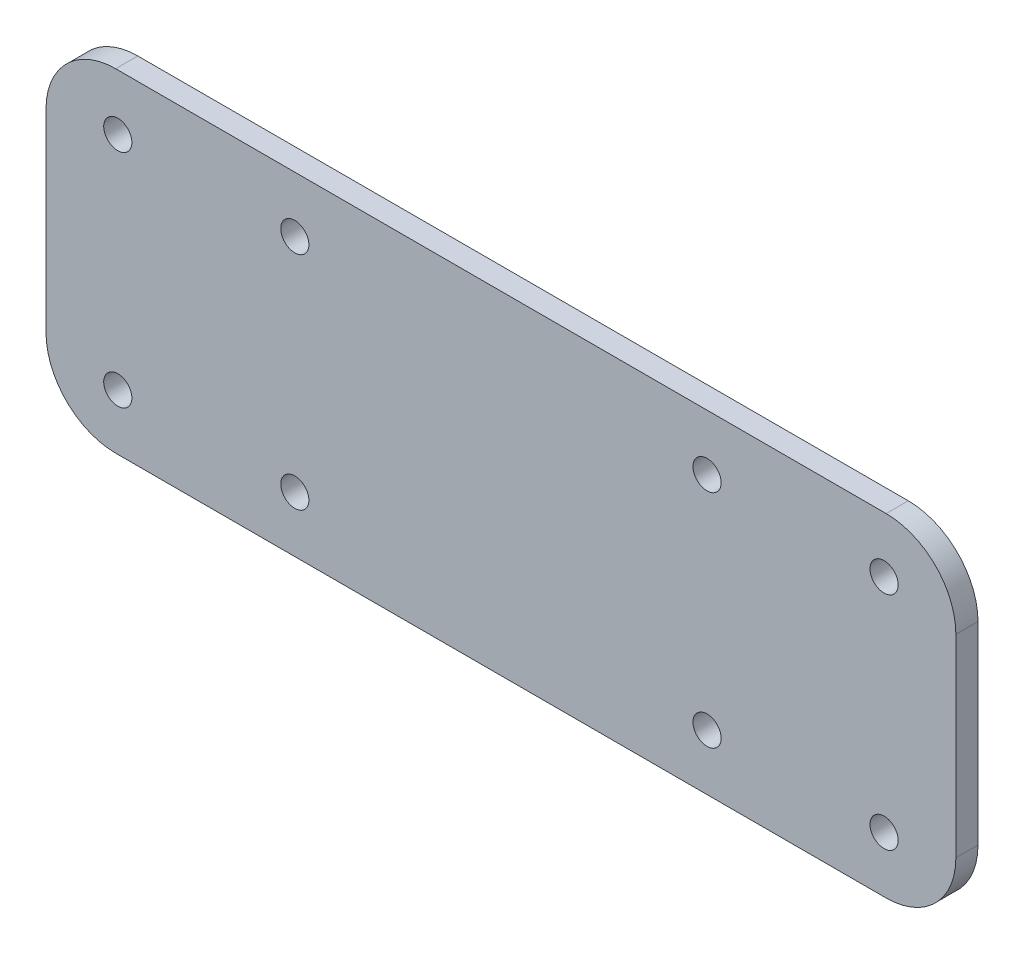
from build123d import *

# Parameters (mm, degrees)
BOSS_EXTRUDE1_DEPTH = 3.175
CUT_EXTRUDE1_DEPTH  = 10
SKETCH3_R           = 2.0193
BOSS_EXTRUDE2_DEPTH = 3.175
FILLET1_R           = 10
FILLET2_R           = 50
SKETCH4_R           = 2.02
CUT_EXTRUDE2_DEPTH  = 10
SKETCH5_R           = 2.0193
BOSS_EXTRUDE3_DEPTH = 3.175
SKETCH6_W           = 3.175
SKETCH6_H           = 346.1216
CUT_EXTRUDE3_DEPTH  = 131.549169731


with BuildPart() as part:
    # Sketch1 → Boss-Extrude1 (new body)
    with BuildSketch(Plane.XY):
        Polygon((165.934536959, -16.66935), (157.315236959, -8.05005), (115.359952094, -8.05005), (89.959952094, -8.05005), (48.004667228, -8.05005), (39.385367228, -16.66935), (39.385367228, -40.05005), (39.385367228, -52.41105), (165.934536959, -56.67505), (165.934536959, -42.05005), align=None)
        with BuildLine():
            ThreePointArc((47.685367228, -44.38075), (49.704667228, -46.40005), (47.685367228, -48.41935))
            ThreePointArc((47.685367228, -48.41935), (45.666067228, -46.40005), (47.685367228, -44.38075))
        make_face(mode=Mode.SUBTRACT)
        with BuildLine():
            ThreePointArc((47.685367228, -12.63075), (49.704667228, -14.65005), (47.685367228, -16.66935))
            ThreePointArc((47.685367228, -16.66935), (45.666067228, -14.65005), (47.685367228, -12.63075))
        make_face(mode=Mode.SUBTRACT)
        with BuildLine():
            ThreePointArc((73.085367228, -44.38075), (75.104667228, -46.40005), (73.085367228, -48.41935))
            ThreePointArc((73.085367228, -48.41935), (71.066067228, -46.40005), (73.085367228, -44.38075))
        make_face(mode=Mode.SUBTRACT)
        with BuildLine():
            ThreePointArc((73.085367228, -12.63075), (75.104667228, -14.65005), (73.085367228, -16.66935))
            ThreePointArc((73.085367228, -16.66935), (71.066067228, -14.65005), (73.085367228, -12.63075))
        make_face(mode=Mode.SUBTRACT)
        with BuildLine():
            ThreePointArc((132.234536959, -44.38075), (134.253836959, -46.40005), (132.234536959, -48.41935))
            ThreePointArc((132.234536959, -48.41935), (130.215236959, -46.40005), (132.234536959, -44.38075))
        make_face(mode=Mode.SUBTRACT)
        with BuildLine():
            ThreePointArc((132.234536959, -12.63075), (134.253836959, -14.65005), (132.234536959, -16.66935))
            ThreePointArc((132.234536959, -16.66935), (130.215236959, -14.65005), (132.234536959, -12.63075))
        make_face(mode=Mode.SUBTRACT)
        with BuildLine():
            ThreePointArc((157.634536959, -44.38075), (159.653836959, -46.40005), (157.634536959, -48.41935))
            ThreePointArc((157.634536959, -48.41935), (155.615236959, -46.40005), (157.634536959, -44.38075))
        make_face(mode=Mode.SUBTRACT)
        with BuildLine():
            ThreePointArc((157.634536959, -12.63075), (159.653836959, -14.65005), (157.634536959, -16.66935))
            ThreePointArc((157.634536959, -16.66935), (155.615236959, -14.65005), (157.634536959, -12.63075))
        make_face(mode=Mode.SUBTRACT)
        Polygon((115.359952094, -8.05005), (157.315236959, -8.05005), (115.359952094, 33.905234866), align=None)
        Polygon((89.959952094, -8.05005), (115.359952094, -8.05005), (115.359952094, 33.905234866), (115.359952094, 203.394265134), (115.359952094, 245.34955), (89.959952094, 245.34955), (89.959952094, 203.394265134), (89.959952094, 33.905234866), align=None)
        Polygon((48.004667228, -8.05005), (89.959952094, -8.05005), (89.959952094, 33.905234866), align=None)
        Polygon((89.959952094, 245.34955), (115.359952094, 245.34955), (157.315236959, 245.34955), (165.934536959, 253.96885), (165.934536959, 279.34955), (165.934536959, 293.97455), (39.385367228, 289.71055), (39.385367228, 277.34955), (39.385367228, 253.96885), (48.004667228, 245.34955), align=None)
        with BuildLine():
            ThreePointArc((47.685367228, 253.96885), (49.704667228, 251.94955), (47.685367228, 249.93025))
            ThreePointArc((47.685367228, 249.93025), (45.666067228, 251.94955), (47.685367228, 253.96885))
        make_face(mode=Mode.SUBTRACT)
        with BuildLine():
            ThreePointArc((47.685367228, 285.71885), (49.704667228, 283.69955), (47.685367228, 281.68025))
            ThreePointArc((47.685367228, 281.68025), (45.666067228, 283.69955), (47.685367228, 285.71885))
        make_face(mode=Mode.SUBTRACT)
        with BuildLine():
            ThreePointArc((73.085367228, 253.96885), (75.104667228, 251.94955), (73.085367228, 249.93025))
            ThreePointArc((73.085367228, 249.93025), (71.066067228, 251.94955), (73.085367228, 253.96885))
        make_face(mode=Mode.SUBTRACT)
        with BuildLine():
            ThreePointArc((73.085367228, 285.71885), (75.104667228, 283.69955), (73.085367228, 281.68025))
            ThreePointArc((73.085367228, 281.68025), (71.066067228, 283.69955), (73.085367228, 285.71885))
        make_face(mode=Mode.SUBTRACT)
        with BuildLine():
            ThreePointArc((132.234536959, 253.96885), (134.253836959, 251.94955), (132.234536959, 249.93025))
            ThreePointArc((132.234536959, 249.93025), (130.215236959, 251.94955), (132.234536959, 253.96885))
        make_face(mode=Mode.SUBTRACT)
        with BuildLine():
            ThreePointArc((157.634536959, 253.96885), (159.653836959, 251.94955), (157.634536959, 249.93025))
            ThreePointArc((157.634536959, 249.93025), (155.615236959, 251.94955), (157.634536959, 253.96885))
        make_face(mode=Mode.SUBTRACT)
        with BuildLine():
            ThreePointArc((157.634536959, 285.71885), (159.653836959, 283.69955), (157.634536959, 281.68025))
            ThreePointArc((157.634536959, 281.68025), (155.615236959, 283.69955), (157.634536959, 285.71885))
        make_face(mode=Mode.SUBTRACT)
        Polygon((115.359952094, 245.34955), (115.359952094, 203.394265134), (157.315236959, 245.34955), align=None)
        Polygon((48.004667228, 245.34955), (89.959952094, 203.394265134), (89.959952094, 245.34955), align=None)
    extrude(amount=BOSS_EXTRUDE1_DEPTH)

    # Sketch2 → Cut-Extrude1 (cut)
    with BuildSketch(Plane.XY.offset(3.175)):
        Polygon((84.385367228, -52.41105), (39.385367228, -52.41105), (165.934536959, -56.67505), (165.934536959, -52.41105), (120.934536959, -52.41105), align=None)
        Polygon((120.934536959, 289.71055), (165.934536959, 289.71055), (165.934536959, 293.97455), (39.385367228, 289.71055), (84.385367228, 289.71055), align=None)
    extrude(amount=-CUT_EXTRUDE1_DEPTH, mode=Mode.SUBTRACT)

    # Sketch3 → Boss-Extrude2 (add)
    with BuildSketch(Plane.XY.offset(3.175)):
        Polygon((37.385367228, -15.840922875), (37.385367228, -54.41105), (167.934536959, -54.41105), (167.934536959, -15.840922875), (117.359952094, 34.73366199), (117.359952094, 202.56583801), (167.934536959, 253.140422875), (167.934536959, 291.71055), (37.385367228, 291.71055), (37.385367228, 253.140422875), (87.959952094, 202.56583801), (87.959952094, 34.73366199), align=None)
        with Locations((132.234536959, -46.40005)):
            Circle(SKETCH3_R, mode=Mode.SUBTRACT)
        with Locations((132.234536959, -14.65005)):
            Circle(SKETCH3_R, mode=Mode.SUBTRACT)
        with Locations((47.685367228, -14.65005)):
            Circle(SKETCH3_R, mode=Mode.SUBTRACT)
        with Locations((47.685367228, -46.40005)):
            Circle(SKETCH3_R, mode=Mode.SUBTRACT)
        with Locations((73.085367228, -46.40005)):
            Circle(SKETCH3_R, mode=Mode.SUBTRACT)
        with Locations((73.085367228, -14.65005)):
            Circle(SKETCH3_R, mode=Mode.SUBTRACT)
        with Locations((157.634536959, -14.65005)):
            Circle(SKETCH3_R, mode=Mode.SUBTRACT)
        with Locations((157.634536959, -46.40005)):
            Circle(SKETCH3_R, mode=Mode.SUBTRACT)
        with Locations((132.234536959, 251.94955)):
            Circle(SKETCH3_R, mode=Mode.SUBTRACT)
        with Locations((73.085367228, 251.94955)):
            Circle(SKETCH3_R, mode=Mode.SUBTRACT)
        with Locations((157.634536959, 251.94955)):
            Circle(SKETCH3_R, mode=Mode.SUBTRACT)
        with Locations((47.685367228, 251.94955)):
            Circle(SKETCH3_R, mode=Mode.SUBTRACT)
        with Locations((47.685367228, 283.69955)):
            Circle(SKETCH3_R, mode=Mode.SUBTRACT)
        with Locations((73.085367228, 283.69955)):
            Circle(SKETCH3_R, mode=Mode.SUBTRACT)
        with Locations((157.634536959, 283.69955)):
            Circle(SKETCH3_R, mode=Mode.SUBTRACT)
    extrude(amount=-BOSS_EXTRUDE2_DEPTH)

    # Fillet1
    fillet1_edges = [part.edges().sort_by_distance(p)[0] for p in [
        (37.385367228, -54.41105, 1.5875),
        (167.934536959, -54.41105, 1.5875),
        (167.934536959, -15.840922875, 1.5875),
        (167.934536959, 253.140422875, 1.5875),
        (167.934536959, 291.71055, 1.5875),
        (37.385367228, 291.71055, 1.5875),
        (37.385367228, 253.140422875, 1.5875),
        (37.385367228, -15.840922875, 1.5875),
    ]]
    fillet(fillet1_edges, radius=FILLET1_R)

    # Fillet2
    fillet2_edges = [part.edges().sort_by_distance(p)[0] for p in [
        (117.359952094, 34.73366199, 1.5875),
        (117.359952094, 202.56583801, 1.5875),
        (87.959952094, 202.56583801, 1.5875),
        (87.959952094, 34.73366199, 1.5875),
    ]]
    fillet(fillet2_edges, radius=FILLET2_R)

    # Sketch4 → Cut-Extrude2 (cut)
    with BuildSketch(Plane.XY.offset(3.175)):
        with Locations((132.234536959, 283.69955)):
            Circle(SKETCH4_R)
    extrude(amount=-CUT_EXTRUDE2_DEPTH, mode=Mode.SUBTRACT)

    # Sketch5 → Boss-Extrude3 (add)
    with BuildSketch(Plane.XY.offset(3.175)):
        with BuildLine():
            Line((167.934536959, -44.41105), (167.934536959, -16.63905))
            ThreePointArc((167.934536959, -16.63905), (165.005604771, -9.567982188), (157.934536959, -6.63905))
            Line((157.934536959, -6.63905), (47.385367228, -6.63905))
            ThreePointArc((47.385367228, -6.63905), (40.314299416, -9.567982188), (37.385367228, -16.63905))
            Line((37.385367228, -16.63905), (37.385367228, -44.41105))
            ThreePointArc((37.385367228, -44.41105), (40.314299416, -51.482117812), (47.385367228, -54.41105))
            Line((47.385367228, -54.41105), (157.934536959, -54.41105))
            ThreePointArc((157.934536959, -54.41105), (165.005604771, -51.482117812), (167.934536959, -44.41105))
        make_face()
        with Locations((47.685367228, -46.40005)):
            Circle(SKETCH5_R, mode=Mode.SUBTRACT)
        with Locations((73.085367228, -46.40005)):
            Circle(SKETCH5_R, mode=Mode.SUBTRACT)
        with Locations((132.234536959, -46.40005)):
            Circle(SKETCH5_R, mode=Mode.SUBTRACT)
        with Locations((157.634536959, -46.40005)):
            Circle(SKETCH5_R, mode=Mode.SUBTRACT)
        with Locations((47.685367228, -14.65005)):
            Circle(SKETCH5_R, mode=Mode.SUBTRACT)
        with Locations((73.085367228, -14.65005)):
            Circle(SKETCH5_R, mode=Mode.SUBTRACT)
        with Locations((132.234536959, -14.65005)):
            Circle(SKETCH5_R, mode=Mode.SUBTRACT)
        with Locations((157.634536959, -14.65005)):
            Circle(SKETCH5_R, mode=Mode.SUBTRACT)
    extrude(amount=BOSS_EXTRUDE3_DEPTH)

    # Sketch6 → Cut-Extrude3 (cut, through all)
    with BuildSketch(Plane.ZY.offset(-37.385367228)):
        with Locations((1.5875, 118.64975)):
            Rectangle(SKETCH6_W, SKETCH6_H)
    extrude(amount=-CUT_EXTRUDE3_DEPTH, mode=Mode.SUBTRACT)


solid = part.part
